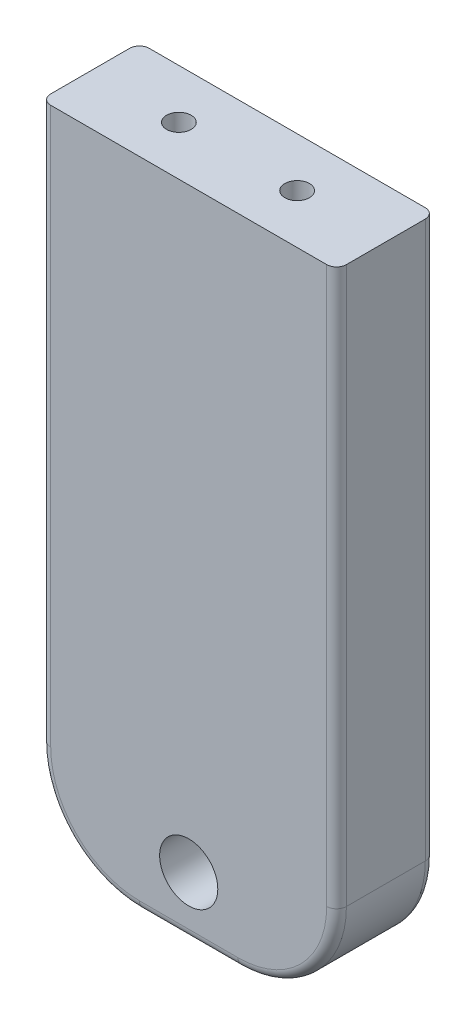
from build123d import *

# Parameters (mm, degrees)
SKETCH1_W                 = 30
SKETCH1_H                 = 66.4
BOSS_EXTRUDE1_DEPTH       = 5
F_6_0MM_DOWEL_HOLE1_D     = 5.9
M3X0_5_TAPPED_HOLE1_D     = 2.5
M3X0_5_TAPPED_HOLE1_DEPTH = 21
M3X0_5_TAPPED_HOLE1_TIP   = 0.751075774
FILLET1_R                 = 10
FILLET2_R                 = 1


with BuildPart() as part:
    # Sketch1 → Boss-Extrude1 (new body, symmetric)
    with BuildSketch(Plane.XY):
        Rectangle(SKETCH1_W, SKETCH1_H)
    extrude(amount=BOSS_EXTRUDE1_DEPTH, both=True)

    # Ø6.0mm Dowel Hole1 (through all)
    with Locations(Plane.XY.offset(5)):
        with Locations((0, -27.2)):
            Hole(F_6_0MM_DOWEL_HOLE1_D / 2)

    # M3x0.5 Tapped Hole1
    with Locations(Plane(origin=(0, 33.2, 0), x_dir=(1, 0, 0), z_dir=(0, 1, 0))):
        with Locations((-6, 0), (6, 0)):
            Hole(M3X0_5_TAPPED_HOLE1_D / 2, depth=M3X0_5_TAPPED_HOLE1_DEPTH)
            with Locations((0, 0, -(M3X0_5_TAPPED_HOLE1_DEPTH + M3X0_5_TAPPED_HOLE1_TIP / 2))):  # 118° drill point
                Cone(0, M3X0_5_TAPPED_HOLE1_D / 2, M3X0_5_TAPPED_HOLE1_TIP, mode=Mode.SUBTRACT)

    # Fillet1
    fillet1_edges = [part.edges().sort_by_distance(p)[0] for p in [
        (15, -33.2, 0),
        (-15, -33.2, 0),
    ]]
    fillet(fillet1_edges, radius=FILLET1_R)

    # Fillet2
    fillet2_edges = [part.edges().sort_by_distance(p)[0] for p in [
        (15, 5, 5),
        (0, -33.2, -5),
        (0, -33.2, 5),
        (12.071067812, -30.271067812, -5),
        (-12.071067812, -30.271067812, -5),
        (12.071067812, -30.271067812, 5),
        (-12.071067812, -30.271067812, 5),
        (-15, 5, 5),
        (15, 5, -5),
        (-15, 5, -5),
    ]]
    fillet(fillet2_edges, radius=FILLET2_R)


solid = part.part
